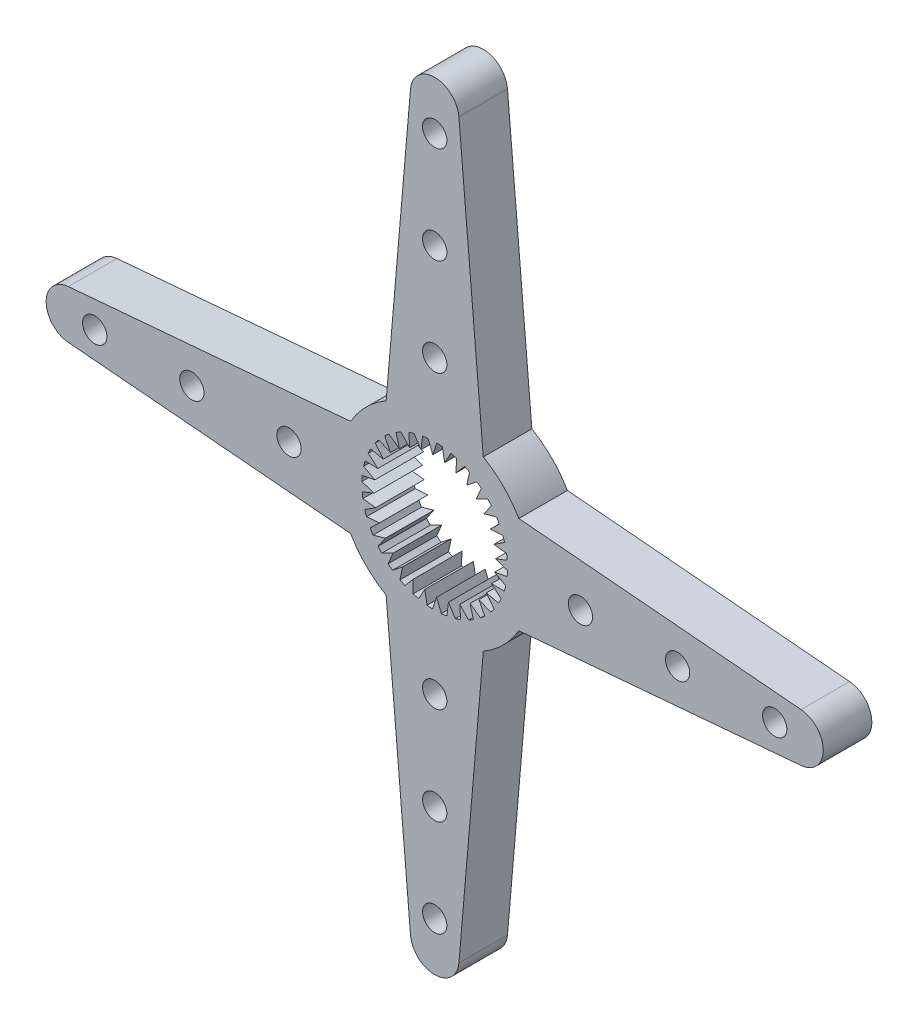
from build123d import *

# Parameters (mm, degrees)
EXTRUDE1_DEPTH     = 2
SKETCH2_R          = 0.5
CUT_EXTRUDE1_DEPTH = 2
CIRPATTERN1_COUNT  = 4
CUT_EXTRUDE2_DEPTH = 2


with BuildPart() as part:
    # Sketch1 → Extrude1 (new body)
    with BuildSketch(Plane.XY):
        with BuildLine():
            Line((-2, 3.464101615), (-0.996291428, 15.086042961))
            ThreePointArc((-0.996291428, 15.086042961), (0, 16), (0.996291428, 15.086042961))
            Line((0.996291428, 15.086042961), (2, 3.464101615))
            ThreePointArc((2, 3.464101615), (2.828427125, 2.828427125), (3.464101615, 2))
            Line((3.464101615, 2), (15.086042961, 0.996291428))
            ThreePointArc((15.086042961, 0.996291428), (16, 0), (15.086042961, -0.996291428))
            Line((15.086042961, -0.996291428), (3.464101615, -2))
            ThreePointArc((3.464101615, -2), (2.828427125, -2.828427125), (2, -3.464101615))
            Line((2, -3.464101615), (0.996291428, -15.086042961))
            ThreePointArc((0.996291428, -15.086042961), (0, -16), (-0.996291428, -15.086042961))
            Line((-0.996291428, -15.086042961), (-2, -3.464101615))
            ThreePointArc((-2, -3.464101615), (-2.828427125, -2.828427125), (-3.464101615, -2))
            Line((-3.464101615, -2), (-15.086042961, -0.996291428))
            ThreePointArc((-15.086042961, -0.996291428), (-16, 0), (-15.086042961, 0.996291428))
            Line((-15.086042961, 0.996291428), (-3.464101615, 2))
            ThreePointArc((-3.464101615, 2), (-2.828427125, 2.828427125), (-2, 3.464101615))
        make_face()
    extrude(amount=EXTRUDE1_DEPTH)

    # Sketch2 → Cut-Extrude1 (cut)
    with BuildSketch(Plane.XY.offset(2)):
        with Locations((0, 14)):
            Circle(SKETCH2_R)
        with Locations((0, 6)):
            Circle(SKETCH2_R)
        with Locations((0, 10)):
            Circle(SKETCH2_R)
    cut_extrude1 = extrude(amount=-CUT_EXTRUDE1_DEPTH, mode=Mode.SUBTRACT)

    # CirPattern1: Cut-Extrude1 ×4 about axis
    cirpattern1_axis = Axis((0, 0, 0), (0, 0, 1))
    for i in range(1, CIRPATTERN1_COUNT):
        add(cut_extrude1.rotate(cirpattern1_axis, i * 360 / CIRPATTERN1_COUNT), mode=Mode.SUBTRACT)

    # Sketch3 → Cut-Extrude2 (cut)
    with BuildSketch(Plane(origin=(0, 0, 0), x_dir=(-1, 0, 0), z_dir=(0, 0, -1))):
        with BuildLine():
            Line((2.655233037, -1.396330018), (2.278530277, -1.02873698))
            Line((2.278530277, -1.02873698), (2.803385583, -1.068189718))
            ThreePointArc((2.803385583, -1.068189718), (2.842070866, -0.960537971), (2.876623952, -0.85148966))
            Line((2.876623952, -0.85148966), (2.435445586, -0.564450882))
            Line((2.435445586, -0.564450882), (2.957912791, -0.500751356))
            ThreePointArc((2.957912791, -0.500751356), (2.974852933, -0.387620982), (2.987467821, -0.273927032))
            Line((2.987467821, -0.273927032), (2.498768086, -0.078473253))
            Line((2.498768086, -0.078473253), (2.998769069, 0.0859306))
            ThreePointArc((2.998769069, 0.0859306), (2.99331307, 0.200192063), (2.983504977, 0.314162459))
            Line((2.983504977, 0.314162459), (2.46606433, 0.410520059))
            Line((2.46606433, 0.410520059), (2.924384334, 0.669310291))
            ThreePointArc((2.924384334, 0.669310291), (2.896741865, 0.780311839), (2.864887711, 0.890178862))
            Line((2.864887711, 0.890178862), (2.338591105, 0.883737315))
            Line((2.338591105, 0.883737315), (2.737617149, 1.226968763))
            ThreePointArc((2.737617149, 1.226968763), (2.688850494, 1.330444669), (2.636174416, 1.431986191))
            Line((2.636174416, 1.431986191), (2.121247135, 1.322993042))
            Line((2.121247135, 1.322993042), (2.445644872, 1.737475514))
            ThreePointArc((2.445644872, 1.737475514), (2.377628107, 1.829449257), (2.306154417, 1.918763093))
            Line((2.306154417, 1.918763093), (1.822384828, 1.711406889))
            Line((1.822384828, 1.711406889), (2.059687834, 2.181212054))
            ThreePointArc((2.059687834, 2.181212054), (1.975034805, 2.258149136), (1.887510196, 2.331803006))
            Line((1.887510196, 2.331803006), (1.453489293, 2.034052328))
            Line((1.453489293, 2.034052328), (1.594578148, 2.541125839))
            ThreePointArc((1.594578148, 2.541125839), (1.496542023, 2.600069609), (1.396330018, 2.655233037))
            Line((1.396330018, 2.655233037), (1.02873698, 2.278530277))
            Line((1.02873698, 2.278530277), (1.068189718, 2.803385583))
            ThreePointArc((1.068189718, 2.803385583), (0.960537971, 2.842070866), (0.85148966, 2.876623952))
            Line((0.85148966, 2.876623952), (0.564450882, 2.435445586))
            Line((0.564450882, 2.435445586), (0.500751356, 2.957912791))
            ThreePointArc((0.500751356, 2.957912791), (0.387620982, 2.974852933), (0.273927032, 2.987467821))
            Line((0.273927032, 2.987467821), (0.078473253, 2.498768086))
            Line((0.078473253, 2.498768086), (-0.0859306, 2.998769069))
            ThreePointArc((-0.0859306, 2.998769069), (-0.200192063, 2.99331307), (-0.314162459, 2.983504977))
            Line((-0.314162459, 2.983504977), (-0.410520059, 2.46606433))
            Line((-0.410520059, 2.46606433), (-0.669310291, 2.924384334))
            ThreePointArc((-0.669310291, 2.924384334), (-0.780311839, 2.896741865), (-0.890178862, 2.864887711))
            Line((-0.890178862, 2.864887711), (-0.883737315, 2.338591105))
            Line((-0.883737315, 2.338591105), (-1.226968763, 2.737617149))
            ThreePointArc((-1.226968763, 2.737617149), (-1.330444669, 2.688850494), (-1.431986191, 2.636174416))
            Line((-1.431986191, 2.636174416), (-1.322993042, 2.121247135))
            Line((-1.322993042, 2.121247135), (-1.737475514, 2.445644872))
            ThreePointArc((-1.737475514, 2.445644872), (-1.829449257, 2.377628107), (-1.918763093, 2.306154417))
            Line((-1.918763093, 2.306154417), (-1.711406889, 1.822384828))
            Line((-1.711406889, 1.822384828), (-2.181212054, 2.059687834))
            ThreePointArc((-2.181212054, 2.059687834), (-2.258149136, 1.975034805), (-2.331803006, 1.887510196))
            Line((-2.331803006, 1.887510196), (-2.034052328, 1.453489293))
            Line((-2.034052328, 1.453489293), (-2.541125839, 1.594578148))
            ThreePointArc((-2.541125839, 1.594578148), (-2.600069609, 1.496542023), (-2.655233037, 1.396330018))
            Line((-2.655233037, 1.396330018), (-2.278530277, 1.02873698))
            Line((-2.278530277, 1.02873698), (-2.803385583, 1.068189718))
            ThreePointArc((-2.803385583, 1.068189718), (-2.842070866, 0.960537971), (-2.876623952, 0.85148966))
            Line((-2.876623952, 0.85148966), (-2.435445586, 0.564450882))
            Line((-2.435445586, 0.564450882), (-2.957912791, 0.500751356))
            ThreePointArc((-2.957912791, 0.500751356), (-2.974852933, 0.387620982), (-2.987467821, 0.273927032))
            Line((-2.987467821, 0.273927032), (-2.498768086, 0.078473253))
            Line((-2.498768086, 0.078473253), (-2.998769069, -0.0859306))
            ThreePointArc((-2.998769069, -0.0859306), (-2.99331307, -0.200192063), (-2.983504977, -0.314162459))
            Line((-2.983504977, -0.314162459), (-2.46606433, -0.410520059))
            Line((-2.46606433, -0.410520059), (-2.924384334, -0.669310291))
            ThreePointArc((-2.924384334, -0.669310291), (-2.896741865, -0.780311839), (-2.864887711, -0.890178862))
            Line((-2.864887711, -0.890178862), (-2.338591105, -0.883737315))
            Line((-2.338591105, -0.883737315), (-2.737617149, -1.226968763))
            ThreePointArc((-2.737617149, -1.226968763), (-2.688850494, -1.330444669), (-2.636174416, -1.431986191))
            Line((-2.636174416, -1.431986191), (-2.121247135, -1.322993042))
            Line((-2.121247135, -1.322993042), (-2.445644872, -1.737475514))
            ThreePointArc((-2.445644872, -1.737475514), (-2.377628107, -1.829449257), (-2.306154417, -1.918763093))
            Line((-2.306154417, -1.918763093), (-1.822384828, -1.711406889))
            Line((-1.822384828, -1.711406889), (-2.059687834, -2.181212054))
            ThreePointArc((-2.059687834, -2.181212054), (-1.975034805, -2.258149136), (-1.887510196, -2.331803006))
            Line((-1.887510196, -2.331803006), (-1.453489293, -2.034052328))
            Line((-1.453489293, -2.034052328), (-1.594578148, -2.541125839))
            ThreePointArc((-1.594578148, -2.541125839), (-1.496542023, -2.600069609), (-1.396330018, -2.655233037))
            Line((-1.396330018, -2.655233037), (-1.02873698, -2.278530277))
            Line((-1.02873698, -2.278530277), (-1.068189718, -2.803385583))
            ThreePointArc((-1.068189718, -2.803385583), (-0.960537971, -2.842070866), (-0.85148966, -2.876623952))
            Line((-0.85148966, -2.876623952), (-0.564450882, -2.435445586))
            Line((-0.564450882, -2.435445586), (-0.500751356, -2.957912791))
            ThreePointArc((-0.500751356, -2.957912791), (-0.387620982, -2.974852933), (-0.273927032, -2.987467821))
            Line((-0.273927032, -2.987467821), (-0.078473253, -2.498768086))
            Line((-0.078473253, -2.498768086), (0.0859306, -2.998769069))
            ThreePointArc((0.0859306, -2.998769069), (0.200192063, -2.99331307), (0.314162459, -2.983504977))
            Line((0.314162459, -2.983504977), (0.410520059, -2.46606433))
            Line((0.410520059, -2.46606433), (0.669310291, -2.924384334))
            ThreePointArc((0.669310291, -2.924384334), (0.780311839, -2.896741865), (0.890178862, -2.864887711))
            Line((0.890178862, -2.864887711), (0.883737315, -2.338591105))
            Line((0.883737315, -2.338591105), (1.226968763, -2.737617149))
            ThreePointArc((1.226968763, -2.737617149), (1.330444669, -2.688850494), (1.431986191, -2.636174416))
            Line((1.431986191, -2.636174416), (1.322993042, -2.121247135))
            Line((1.322993042, -2.121247135), (1.737475514, -2.445644872))
            ThreePointArc((1.737475514, -2.445644872), (1.829449257, -2.377628107), (1.918763093, -2.306154417))
            Line((1.918763093, -2.306154417), (1.711406889, -1.822384828))
            Line((1.711406889, -1.822384828), (2.181212054, -2.059687834))
            ThreePointArc((2.181212054, -2.059687834), (2.258149136, -1.975034805), (2.331803006, -1.887510196))
            Line((2.331803006, -1.887510196), (2.034052328, -1.453489293))
            Line((2.034052328, -1.453489293), (2.541125839, -1.594578148))
            ThreePointArc((2.541125839, -1.594578148), (2.600069609, -1.496542023), (2.655233037, -1.396330018))
        make_face()
    extrude(amount=-CUT_EXTRUDE2_DEPTH, mode=Mode.SUBTRACT)


solid = part.part
